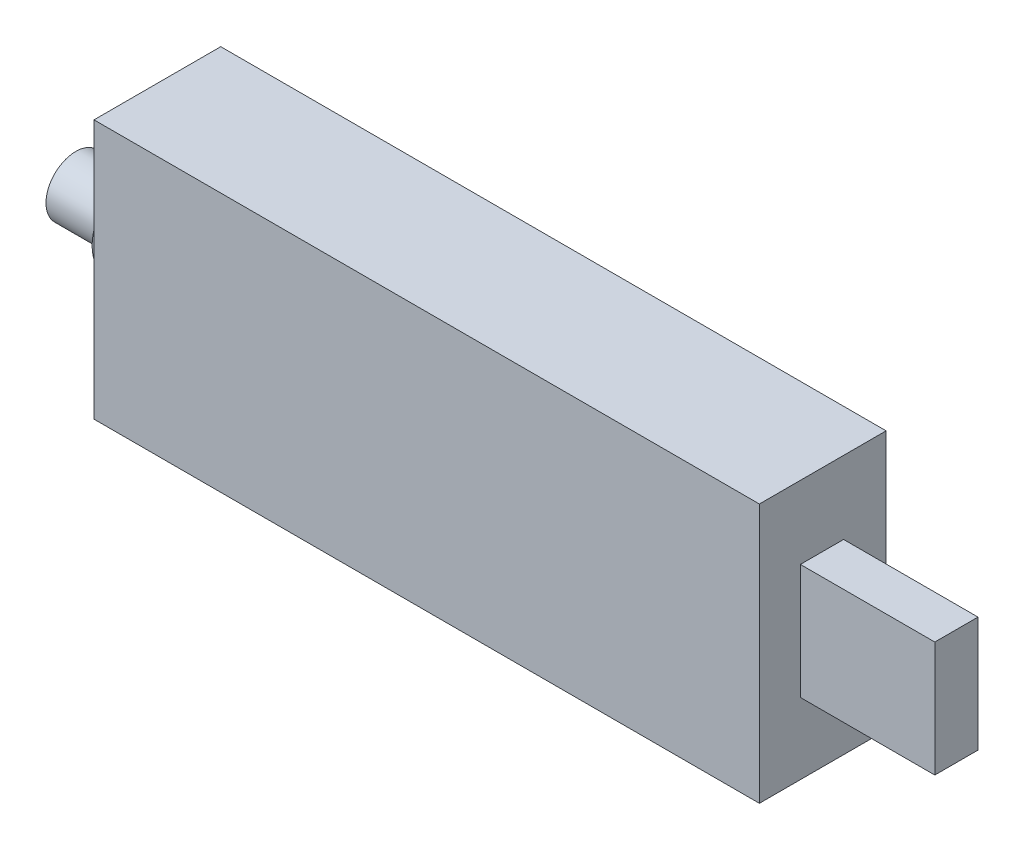
from build123d import *

# Parameters (mm, degrees)
SKETCH1_W           = 69.3
SKETCH1_H           = 27
BOSS_EXTRUDE1_DEPTH = 13.2
SKETCH2_R           = 4.55
BOSS_EXTRUDE2_DEPTH = 2.25
SKETCH3_R           = 3.1
BOSS_EXTRUDE3_DEPTH = 6.25
SKETCH4_W           = 4.5
SKETCH4_H           = 12
BOSS_EXTRUDE4_DEPTH = 14


with BuildPart() as part:
    # Sketch1 → Boss-Extrude1 (new body)
    with BuildSketch(Plane.XY):
        with Locations((-34.65, 13.5)):
            Rectangle(SKETCH1_W, SKETCH1_H)
    extrude(amount=BOSS_EXTRUDE1_DEPTH)

    # Sketch2 → Boss-Extrude2 (add)
    with BuildSketch(Plane.ZY.offset(69.3)):
        with Locations((6.6, 13.5)):
            Circle(SKETCH2_R)
    extrude(amount=BOSS_EXTRUDE2_DEPTH)

    # Sketch3 → Boss-Extrude3 (add)
    with BuildSketch(Plane.ZY.offset(71.55)):
        with Locations((6.6, 13.5)):
            Circle(SKETCH3_R)
    extrude(amount=BOSS_EXTRUDE3_DEPTH)

    # Sketch4 → Boss-Extrude4 (add)
    with BuildSketch(Plane(origin=(0, 0, 0), x_dir=(0, 0, -1), z_dir=(1, 0, 0))):
        with Locations((-6.68005531, 13.414910597)):
            Rectangle(SKETCH4_W, SKETCH4_H)
    extrude(amount=BOSS_EXTRUDE4_DEPTH)


solid = part.part
